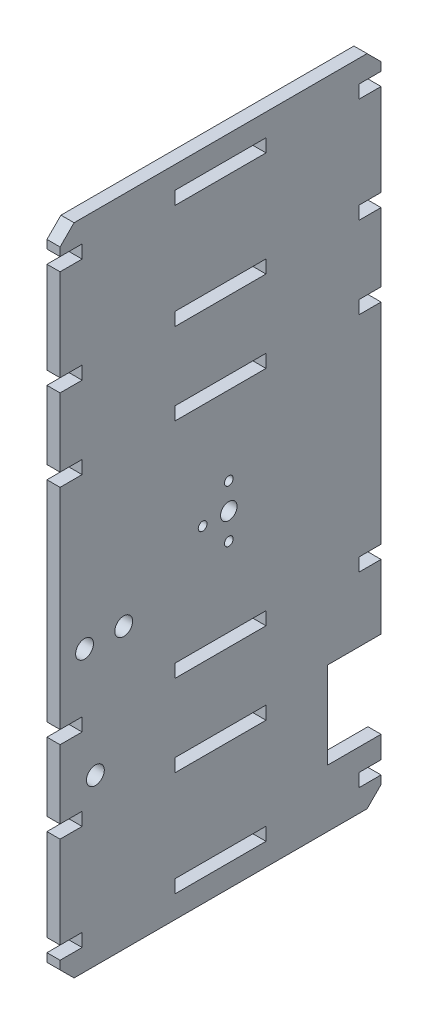
from build123d import *

# Parameters (mm, degrees)
SKETCH1_R           = 1.5875
SKETCH1_R_2         = 3
SKETCH1_R_3         = 3.2385
SKETCH1_W           = 33.02
SKETCH1_H           = 4.7625
BOSS_EXTRUDE1_DEPTH = 4.7625
CHAMFER1_SIZE       = 5.08


with BuildPart() as part:
    # Sketch1 → Boss-Extrude1 (new body)
    with BuildSketch(Plane(origin=(0, 0, 0), x_dir=(0, 0, -1), z_dir=(1, 0, 0))):
        Polygon((-58.293, 118.7905), (58.293, 118.7905), (58.293, 110.6625), (50.293, 110.6625), (50.293, 105.9), (58.293, 105.9), (58.293, 72.5625), (50.293, 72.5625), (50.293, 67.8), (58.293, 67.8), (58.293, 42.8625), (50.293, 42.8625), (50.293, 38.1), (58.293, 38.1), (58.293, -38.1), (50.293, -38.1), (50.293, -42.8625), (58.293, -42.8625), (58.293, -66.374), (38.857, -66.374), (38.857, -97.87), (58.293, -97.87), (58.293, -105.9), (50.293, -105.9), (50.293, -110.6625), (58.293, -110.6625), (58.293, -118.7905), (-58.293, -118.7905), (-58.293, -110.6625), (-50.293, -110.6625), (-50.293, -105.9), (-58.293, -105.9), (-58.293, -72.5625), (-50.293, -72.5625), (-50.293, -67.8), (-58.293, -67.8), (-58.293, -42.8625), (-50.293, -42.8625), (-50.293, -38.1), (-58.293, -38.1), (-58.293, 38.1), (-50.293, 38.1), (-50.293, 42.8625), (-58.293, 42.8625), (-58.293, 67.8), (-50.293, 67.8), (-50.293, 72.5625), (-58.293, 72.5625), (-58.293, 105.9), (-50.293, 105.9), (-50.293, 110.6625), (-58.293, 110.6625), align=None)
        with Locations((3, 9.519071488)):
            Circle(SKETCH1_R, mode=Mode.SUBTRACT)
        with Locations((-6.519071488, 0)):
            Circle(SKETCH1_R, mode=Mode.SUBTRACT)
        with Locations((3, -9.519071488)):
            Circle(SKETCH1_R, mode=Mode.SUBTRACT)
        with Locations((3, 0)):
            Circle(SKETCH1_R_2, mode=Mode.SUBTRACT)
        with Locations((-35.174, -17.15)):
            Circle(SKETCH1_R_3, mode=Mode.SUBTRACT)
        with Locations((-49.398, -17.15)):
            Circle(SKETCH1_R_3, mode=Mode.SUBTRACT)
        with Locations((-45.464, -58.872973782)):
            Circle(SKETCH1_R_3, mode=Mode.SUBTRACT)
        with Locations((0, 108.28125)):
            Rectangle(SKETCH1_W, SKETCH1_H, mode=Mode.SUBTRACT)
        with Locations((0, 70.18125)):
            Rectangle(SKETCH1_W, SKETCH1_H, mode=Mode.SUBTRACT)
        with Locations((0, 40.48125)):
            Rectangle(SKETCH1_W, SKETCH1_H, mode=Mode.SUBTRACT)
        with Locations((0, -40.48125)):
            Rectangle(SKETCH1_W, SKETCH1_H, mode=Mode.SUBTRACT)
        with Locations((0, -70.18125)):
            Rectangle(SKETCH1_W, SKETCH1_H, mode=Mode.SUBTRACT)
        with Locations((0, -108.28125)):
            Rectangle(SKETCH1_W, SKETCH1_H, mode=Mode.SUBTRACT)
    extrude(amount=-BOSS_EXTRUDE1_DEPTH)

    # Chamfer1
    chamfer1_edges = [part.edges().sort_by_distance(p)[0] for p in [
        (-2.38125, 118.7905, 58.293),
        (-2.38125, 118.7905, -58.293),
        (-2.38125, -118.7905, 58.293),
        (-2.38125, -118.7905, -58.293),
    ]]
    chamfer(chamfer1_edges, length=CHAMFER1_SIZE)


solid = part.part
